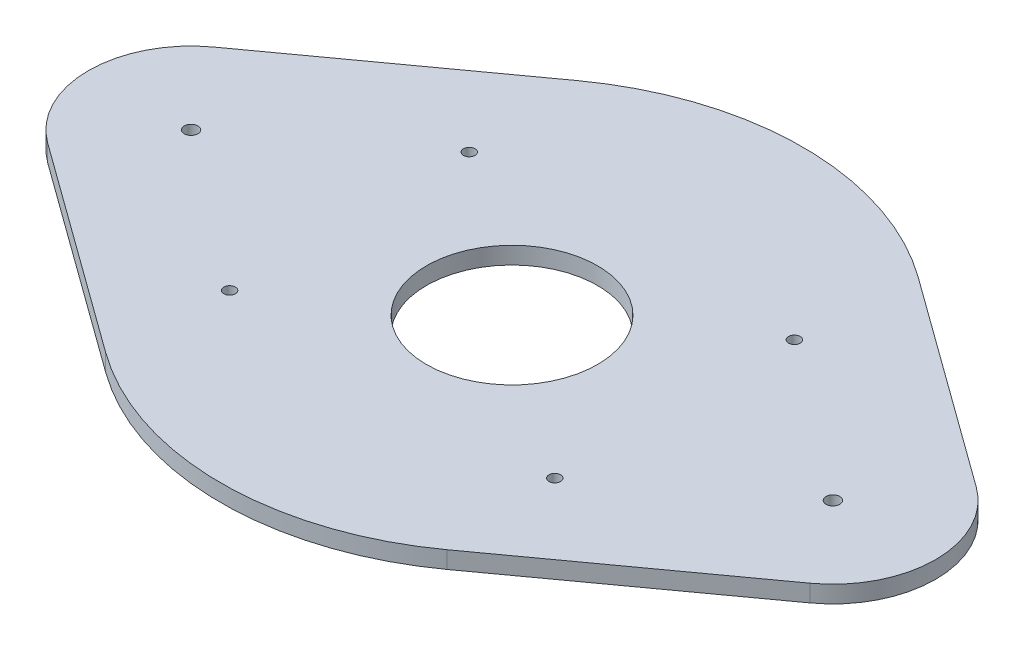
from build123d import *

# Parameters (mm, degrees)
CROQUIS1_R              = 50
CROQUIS1_R_2            = 3.4
CROQUIS1_R_3            = 4
SALIENTE_EXTRUIR1_DEPTH = 10


with BuildPart() as part:
    # Croquis1 → Saliente-Extruir1 (new body)
    with BuildSketch(Plane(origin=(0, 0, 0), x_dir=(1, 0, 0), z_dir=(0, 1, 0))):
        with BuildLine():
            Line((-99.733333333, 137.670847394), (-222.7, 48.589710845))
            ThreePointArc((-222.7, 48.589710845), (-247.5, 0), (-222.7, -48.589710845))
            Line((-222.7, -48.589710845), (-99.733333333, -137.670847394))
            ThreePointArc((-99.733333333, -137.670847394), (0, -170), (99.733333333, -137.670847394))
            Line((99.733333333, -137.670847394), (222.7, -48.589710845))
            ThreePointArc((222.7, -48.589710845), (247.5, 0), (222.7, 48.589710845))
            Line((222.7, 48.589710845), (99.733333333, 137.670847394))
            ThreePointArc((99.733333333, 137.670847394), (0, 170), (-99.733333333, 137.670847394))
        make_face()
        Circle(CROQUIS1_R, mode=Mode.SUBTRACT)
        with Locations((-95, 70)):
            Circle(CROQUIS1_R_2, mode=Mode.SUBTRACT)
        with Locations((95, 70)):
            Circle(CROQUIS1_R_2, mode=Mode.SUBTRACT)
        with Locations((95, -70)):
            Circle(CROQUIS1_R_2, mode=Mode.SUBTRACT)
        with Locations((-95, -70)):
            Circle(CROQUIS1_R_2, mode=Mode.SUBTRACT)
        with Locations((187.5, 0)):
            Circle(CROQUIS1_R_3, mode=Mode.SUBTRACT)
        with Locations((-187.5, 0)):
            Circle(CROQUIS1_R_3, mode=Mode.SUBTRACT)
    extrude(amount=SALIENTE_EXTRUIR1_DEPTH)


solid = part.part
